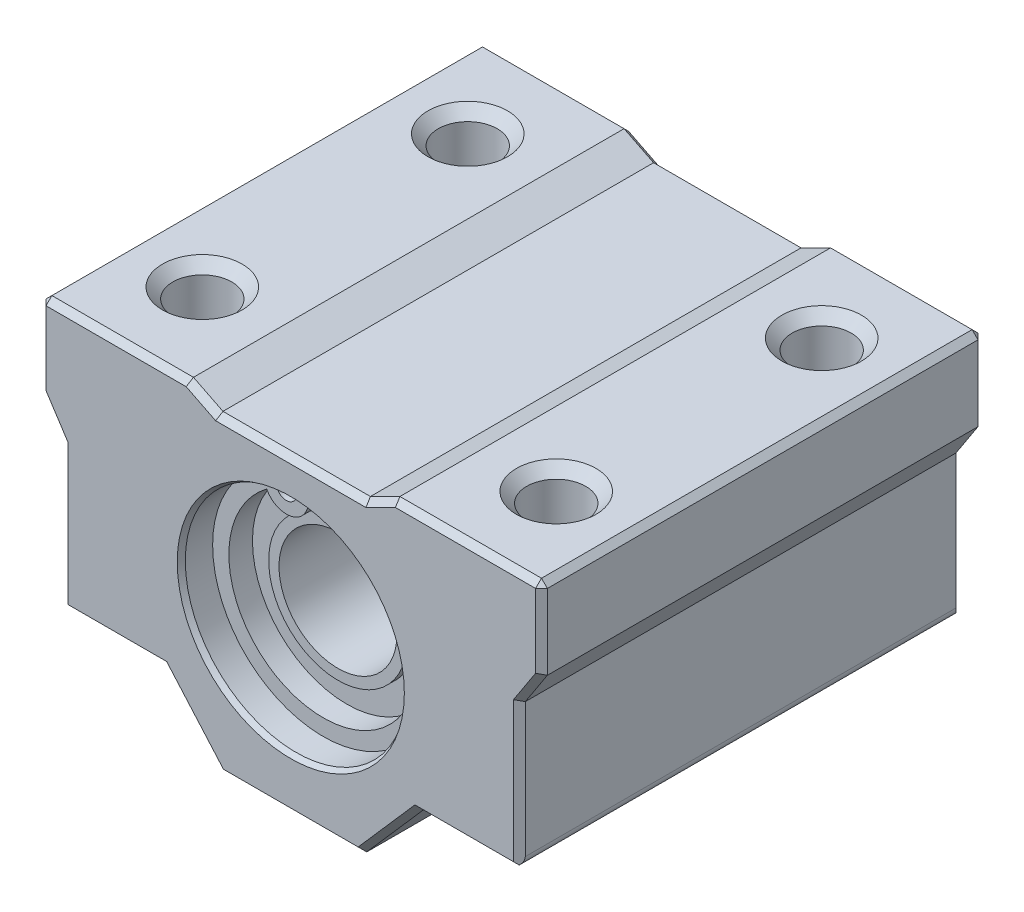
from build123d import *

# Parameters (mm, degrees)
SKETCH1_R             = 7.5
BOSS_EXTRUDE1_DEPTH   = 15
SKETCH3_R             = 0.7
BOSS_EXTRUDE2_DEPTH   = 0.8
CHAFL_N0_SIZE         = 0.2
CHAFL_N0_SIZE2        = 0.346410162
CHAFL_N0_PART_2_SIZE  = 0.2
CHAFL_N0_PART_2_SIZE2 = 0.346410162
CROQUIS1_R            = 2
CORTAR_EXTRUIR1_DEPTH = 20
CHAFL_N1_SIZE         = 0.7
CHAFL_N2_SIZE         = 0.4
REDONDEO1_R           = 0.7


with BuildPart() as part:
    # Sketch1 → Boss-Extrude1 (new body, symmetric)
    with BuildSketch(Plane.XY):
        Polygon((-5, -1), (5, -1), (7, 0), (17, 0), (17, -5.5), (15.5, -7.8), (15.5, -17.6), (8.6, -17.6), (4.75, -22), (-4.75, -22), (-8.6, -17.6), (-15.5, -17.6), (-15.5, -7.8), (-17, -5.5), (-17, 0), (-7, 0), align=None)
        with Locations((0, -11)):
            Circle(SKETCH1_R, mode=Mode.SUBTRACT)
    extrude(amount=BOSS_EXTRUDE1_DEPTH, both=True)

    # Sketch2 → Revolve1 (revolve)
    with BuildSketch(Plane(origin=(0, 0, 0), x_dir=(0, 0, -1), z_dir=(1, 0, 0))):
        Polygon((-12, -3.5), (12, -3.5), (12, -4.6), (11.2, -4.6), (11.2, -6.3), (11.8, -6.3), (11.8, -7), (-11.8, -7), (-11.8, -6.3), (-11.2, -6.3), (-11.2, -4.6), (-12, -4.6), align=None)
    revolve(axis=Axis((0, -11, 30.2753079), (0, 0, -1)))

    # Sketch3 → Boss-Extrude2 (add)
    with BuildSketch(Plane.XY.offset(12)):
        with BuildLine():
            ThreePointArc((2, -3.771583853), (1.369159148, -6.17129169), (3.832579259, -5.874442838))
            ThreePointArc((3.832579259, -5.874442838), (0, -17.4), (-3.832579259, -5.874442838))
            ThreePointArc((-3.832579259, -5.874442838), (-1.369159148, -6.17129169), (-2, -3.771583853))
            ThreePointArc((-2, -3.771583853), (0, -18.5), (2, -3.771583853))
        make_face()
        with Locations((2.5, -5.185797415)):
            Circle(SKETCH3_R, mode=Mode.SUBTRACT)
        with Locations((-2.5, -5.185797415)):
            Circle(SKETCH3_R, mode=Mode.SUBTRACT)
    boss_extrude2 = extrude(amount=BOSS_EXTRUDE2_DEPTH)

    # simetria: Boss-Extrude2 across plane
    add(boss_extrude2.mirror(Plane.XY))

    # Chaflàn0
    chafl_n0_edges = [part.edges().sort_by_distance(p)[0] for p in [
        (-7.5, -11, -15),
    ]]
    chafl_n0_side = [part.faces().sort_by_distance(p)[0] for p in [
        (-7.5, -11, -13.5),
    ]]
    chamfer(chafl_n0_edges, length=CHAFL_N0_SIZE, length2=CHAFL_N0_SIZE2, reference=chafl_n0_side[0])

    # Chaflàn0 part 2
    chafl_n0_part_2_edges = [part.edges().sort_by_distance(p)[0] for p in [
        (-7.5, -11, 15),
    ]]
    chafl_n0_part_2_side = [part.faces().sort_by_distance(p)[0] for p in [
        (0, -1.404969135, 15),
    ]]
    chamfer(chafl_n0_part_2_edges, length=CHAFL_N0_PART_2_SIZE, length2=CHAFL_N0_PART_2_SIZE2, reference=chafl_n0_part_2_side[0])

    # Croquis1 → Cortar-Extruir1 (cut)
    with BuildSketch(Plane(origin=(0, 0, 0), x_dir=(1, 0, 0), z_dir=(0, 1, 0))):
        with Locations((-12, 9)):
            Circle(CROQUIS1_R)
        with Locations((12, 9)):
            Circle(CROQUIS1_R)
        with Locations((-12, -9)):
            Circle(CROQUIS1_R)
        with Locations((12, -9)):
            Circle(CROQUIS1_R)
    extrude(amount=-CORTAR_EXTRUIR1_DEPTH, mode=Mode.SUBTRACT)

    # Chaflán1
    chafl_n1_edges = [part.edges().sort_by_distance(p)[0] for p in [
        (-14, -17.6, -9),
        (-14, 0, -9),
        (10, -17.6, -9),
        (10, 0, -9),
        (-14, -17.6, 9),
        (-14, 0, 9),
        (10, -17.6, 9),
        (10, 0, 9),
    ]]
    chamfer(chafl_n1_edges, length=CHAFL_N1_SIZE)

    # Chaflán2
    chafl_n2_edges = [part.edges().sort_by_distance(p)[0] for p in [
        (-6, -0.5, 15),
        (-12, 0, 15),
        (12, 0, -15),
        (17, -2.75, -15),
        (16.25, -6.65, -15),
        (15.5, -12.7, -15),
        (12.05, -17.6, -15),
        (-17, -2.75, 15),
        (6.675, -19.8, -15),
        (0, -22, -15),
        (-6.675, -19.8, -15),
        (-12.05, -17.6, -15),
        (-15.5, -12.7, -15),
        (-16.25, -6.65, -15),
        (-17, -2.75, -15),
        (-12, 0, -15),
        (-16.25, -6.65, 15),
        (-6, -0.5, -15),
        (0, -1, -15),
        (6, -0.5, -15),
        (-15.5, -12.7, 15),
        (-12.05, -17.6, 15),
        (17, 0, 0),
        (-17, 0, 0),
        (-6.675, -19.8, 15),
        (0, -22, 15),
        (6.675, -19.8, 15),
        (12.05, -17.6, 15),
        (6, -0.5, 15),
        (15.5, -12.7, 15),
        (16.25, -6.65, 15),
        (17, -2.75, 15),
        (12, 0, 15),
        (0, -1, 15),
    ]]
    chamfer(chafl_n2_edges, length=CHAFL_N2_SIZE)

    # Redondeo1
    redondeo1_edges = [part.edges().sort_by_distance(p)[0] for p in [
        (15.5, -17.6, 0),
        (-15.5, -17.6, 0),
    ]]
    fillet(redondeo1_edges, radius=REDONDEO1_R)


solid = part.part
